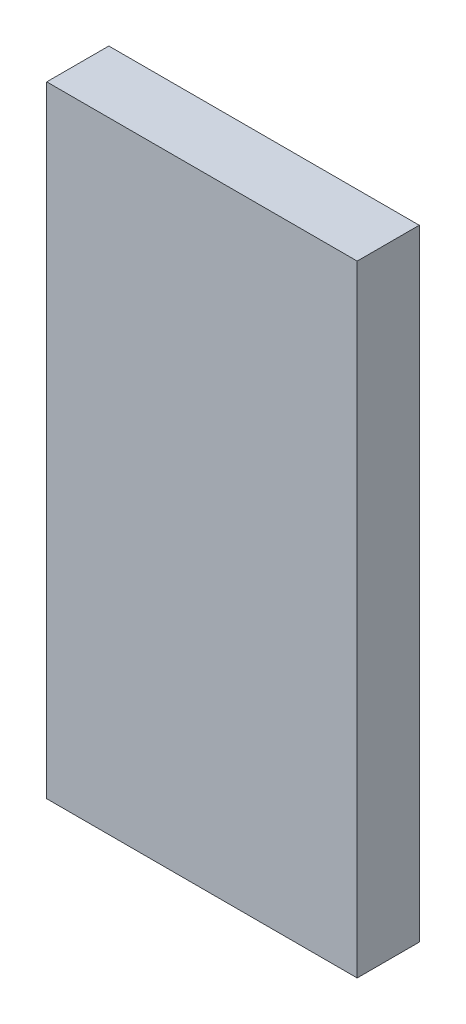
from build123d import *

# Parameters (mm, degrees)
CROQUIS1_W              = 60
CROQUIS1_H              = 120
SALIENTE_EXTRUIR1_DEPTH = 12


with BuildPart() as part:
    # Croquis1 → Saliente-Extruir1 (new body)
    with BuildSketch(Plane.XY):
        Rectangle(CROQUIS1_W, CROQUIS1_H)
    extrude(amount=-SALIENTE_EXTRUIR1_DEPTH)


solid = part.part
